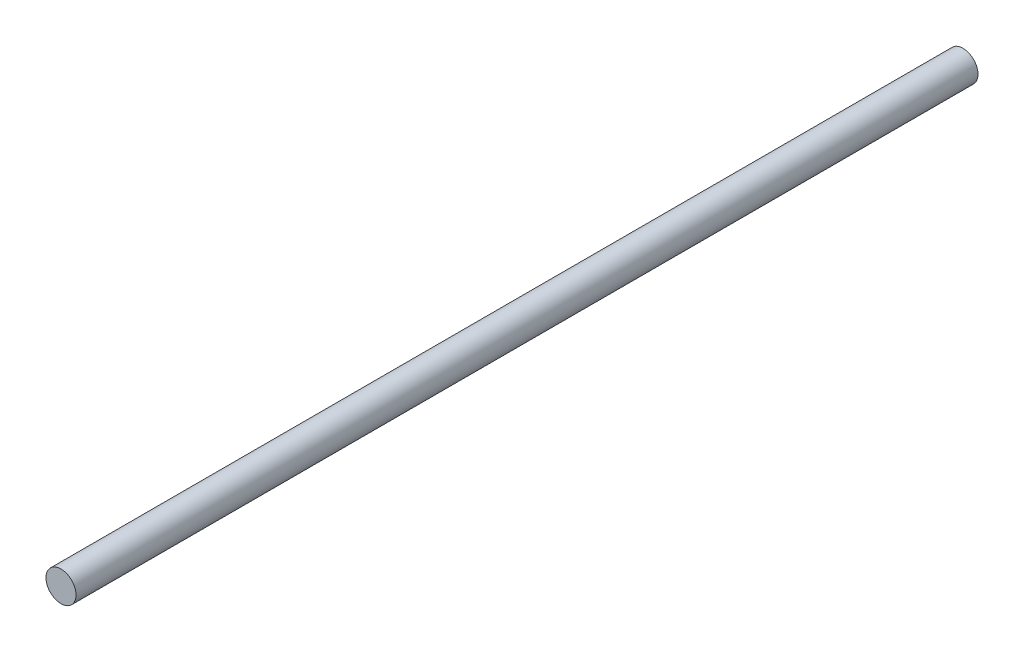
from build123d import *

# Parameters (mm, degrees)
SKETCH1_R           = 10
BOSS_EXTRUDE2_DEPTH = 600


with BuildPart() as part:
    # Sketch1 → Boss-Extrude2 (new body)
    with BuildSketch(Plane.XY):
        Circle(SKETCH1_R)
    extrude(amount=BOSS_EXTRUDE2_DEPTH)


solid = part.part
